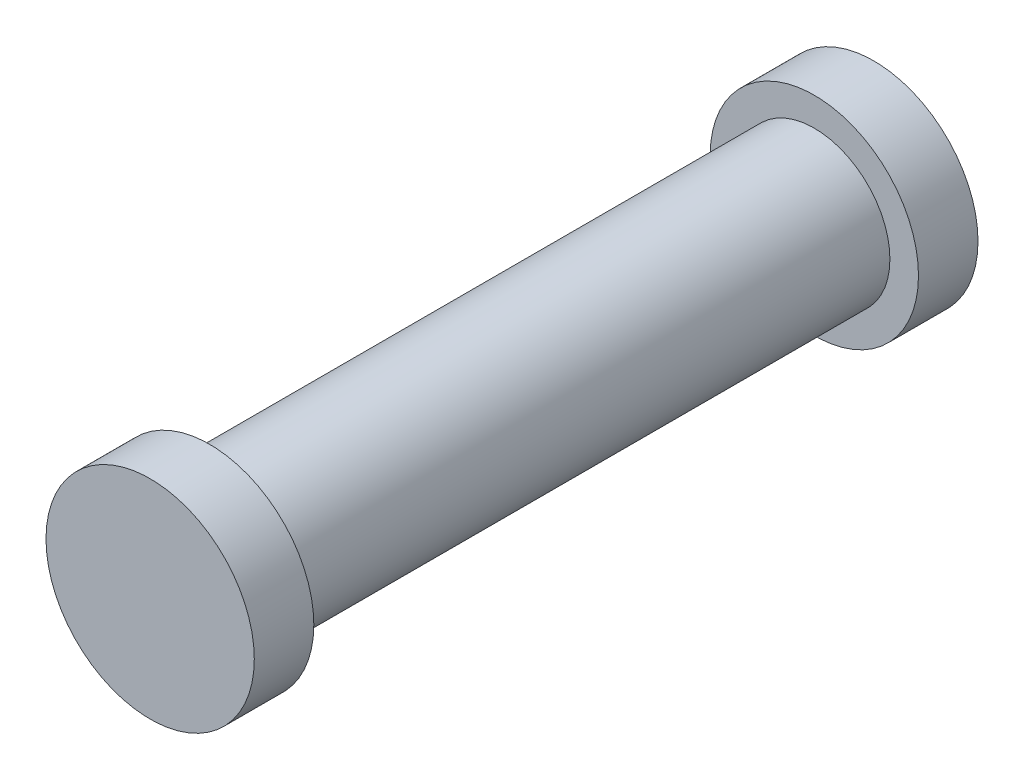
from build123d import *

# Parameters (mm, degrees)
SKETCH1_R           = 12.7
BOSS_EXTRUDE1_DEPTH = 50.8
SKETCH2_R           = 17.5
BOSS_EXTRUDE2_DEPTH = 10


with BuildPart() as part:
    # Sketch1 → Boss-Extrude1 (new, symmetric)
    with BuildSketch(Plane.XY):
        Circle(SKETCH1_R)
    extrude(amount=BOSS_EXTRUDE1_DEPTH, both=True)

    # Sketch2 → Boss-Extrude2 (add)
    with BuildSketch(Plane.XY.offset(50.8)):
        Circle(SKETCH2_R)
    boss_extrude2 = extrude(amount=BOSS_EXTRUDE2_DEPTH)

    # Mirror1: Boss-Extrude2 across plane
    add(boss_extrude2.mirror(Plane.XY))


solid = part.part
